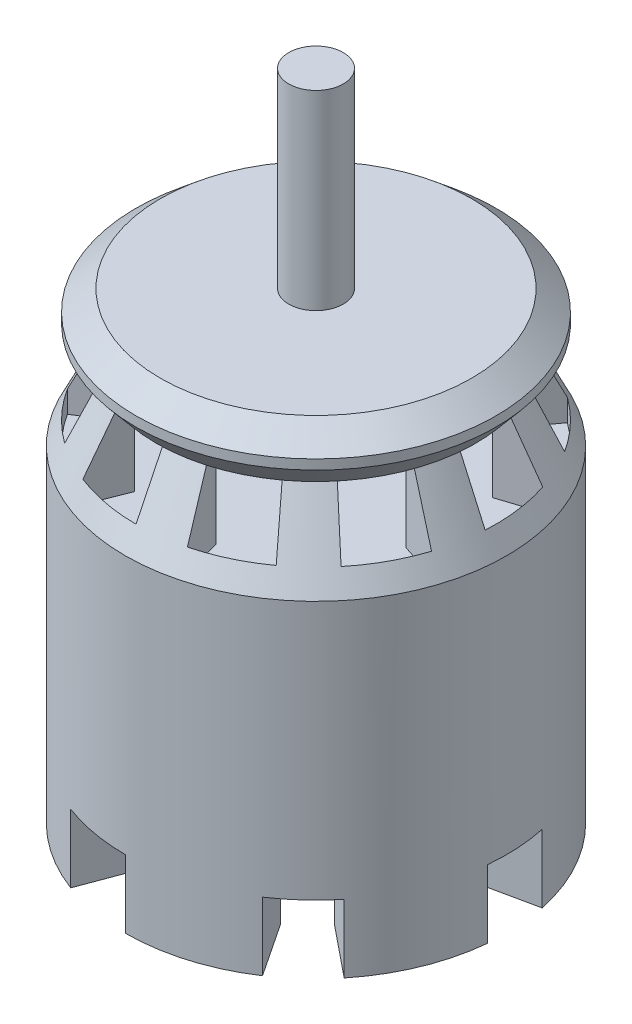
from build123d import *

# Parameters (mm, degrees)
SKETCH1_R             = 14
BOSS_EXTRUDE1_DEPTH   = 25
CHAMFER1_SIZE         = 6
CHAMFER1_SIZE2        = 2.926395531
CUT_EXTRUDE1_DEPTH    = 6
CIRPATTERN1_COUNT     = 10
SKETCH3_R             = 13.212713
BOSS_EXTRUDE2_DEPTH   = 4
CHAMFER2_SIZE         = 1.5
CHAMFER2_SIZE2        = 1.787630389
CHAMFER2_PART_2_SIZE  = 1.5
CHAMFER2_PART_2_SIZE2 = 1.787630389
SKETCH4_R             = 2
BOSS_EXTRUDE3_DEPTH   = 24
BOSS_EXTRUDE4_DEPTH   = 5
CIRPATTERN2_COUNT     = 7
CIRPATTERN2_ANGLE     = 306


with BuildPart() as part:
    # Sketch1 → Boss-Extrude1 (new body)
    with BuildSketch(Plane(origin=(0, 0, 0), x_dir=(1, 0, 0), z_dir=(0, 1, 0))):
        Circle(SKETCH1_R)
    extrude(amount=BOSS_EXTRUDE1_DEPTH)

    # Chamfer1
    chamfer1_edges = [part.edges().sort_by_distance(p)[0] for p in [
        (-14, 25, 0),
    ]]
    chamfer1_side = [part.faces().sort_by_distance(p)[0] for p in [
        (-14, 12.5, 0),
    ]]
    chamfer(chamfer1_edges, length=CHAMFER1_SIZE, length2=CHAMFER1_SIZE2, reference=chamfer1_side[0])

    # Sketch2 → Cut-Extrude1 (cut)
    with BuildSketch(Plane(origin=(0, 25, 0), x_dir=(1, 0, 0), z_dir=(0, 1, 0))):
        with BuildLine():
            Line((0, 10.291206374), (0, 13.212713))
            ThreePointArc((0, 13.212713), (2.447017171, 12.98414001), (4.80937012, 12.306329423))
            Line((4.80937012, 12.306329423), (3.745954402, 9.585236265))
            ThreePointArc((3.745954402, 9.585236265), (-1.905949119, -10.113173913), (0, 10.291206374))
        make_face()
    cut_extrude1 = extrude(amount=-CUT_EXTRUDE1_DEPTH, mode=Mode.SUBTRACT)

    # CirPattern1: Cut-Extrude1 ×10 about axis
    cirpattern1_axis = Axis((0, 0, 0), (0, 1, 0))
    for i in range(1, CIRPATTERN1_COUNT):
        add(cut_extrude1.rotate(cirpattern1_axis, i * 360 / CIRPATTERN1_COUNT), mode=Mode.SUBTRACT)

    # Sketch3 → Boss-Extrude2 (add)
    with BuildSketch(Plane(origin=(0, 25, 0), x_dir=(1, 0, 0), z_dir=(0, 1, 0))):
        Circle(SKETCH3_R)
    extrude(amount=BOSS_EXTRUDE2_DEPTH)

    # Chamfer2
    chamfer2_edges = [part.edges().sort_by_distance(p)[0] for p in [
        (-13.212713, 25, 0),
    ]]
    chamfer2_side = [part.faces().sort_by_distance(p)[0] for p in [
        (0, 25, 0),
    ]]
    chamfer(chamfer2_edges, length=CHAMFER2_SIZE, length2=CHAMFER2_SIZE2, reference=chamfer2_side[0])

    # Chamfer2 part 2
    chamfer2_part_2_edges = [part.edges().sort_by_distance(p)[0] for p in [
        (-13.212713, 29, 0),
    ]]
    chamfer2_part_2_side = [part.faces().sort_by_distance(p)[0] for p in [
        (-13.212713, 27, 0),
    ]]
    chamfer(chamfer2_part_2_edges, length=CHAMFER2_PART_2_SIZE, length2=CHAMFER2_PART_2_SIZE2, reference=chamfer2_part_2_side[0])

    # Sketch4 → Boss-Extrude3 (add)
    with BuildSketch(Plane(origin=(0, 19, 0), x_dir=(1, 0, 0), z_dir=(0, 1, 0))):
        Circle(SKETCH4_R)
    extrude(amount=BOSS_EXTRUDE3_DEPTH)

    # Sketch5 → Boss-Extrude4 (add)
    with BuildSketch(Plane.XZ):
        with BuildLine():
            Line((0, 9.308060502), (0, 14))
            ThreePointArc((0, 14), (4.041174246, 13.404063217), (7.738307866, 11.666987245))
            Line((7.738307866, 11.666987245), (5.1449027, 7.756930225))
            ThreePointArc((5.1449027, 7.756930225), (2.686821027, 8.911845099), (0, 9.308060502))
        make_face()
    boss_extrude4 = extrude(amount=BOSS_EXTRUDE4_DEPTH)

    # CirPattern2: Boss-Extrude4 ×7 about axis
    cirpattern2_axis = Axis((0, 0, 0), (0, 1, 0))
    for i in range(1, CIRPATTERN2_COUNT):
        add(boss_extrude4.rotate(cirpattern2_axis, i * CIRPATTERN2_ANGLE / (CIRPATTERN2_COUNT - 1)))


solid = part.part
